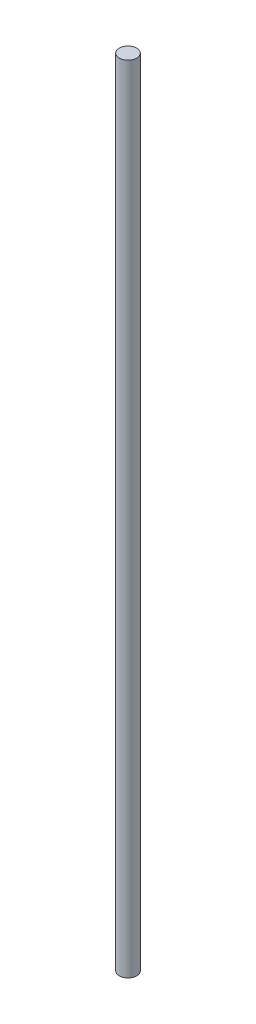
from build123d import *

# Parameters (mm, degrees)
SKETCH1_R           = 2.5
BOSS_EXTRUDE1_DEPTH = 228.08


with BuildPart() as part:
    # Sketch1 → Boss-Extrude1 (new body)
    with BuildSketch(Plane(origin=(0, 0, 0), x_dir=(1, 0, 0), z_dir=(0, 1, 0))):
        Circle(SKETCH1_R)
    extrude(amount=BOSS_EXTRUDE1_DEPTH)


solid = part.part
